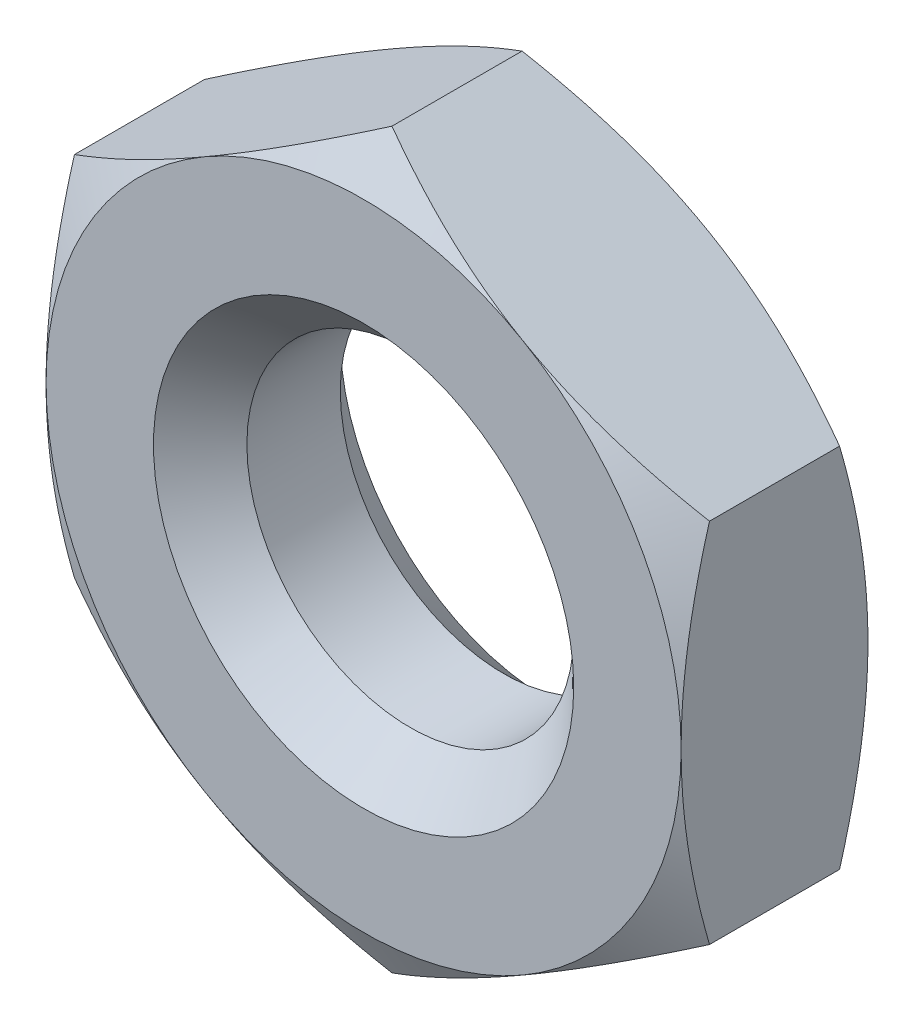
from build123d import *

# Parameters (mm, degrees)
SKETCH_1_R      = 4.375
EXTRUDE_1_DEPTH = 5
CHAMFER_1_SIZE  = 1.25


with BuildPart() as part:
    # Эскиз1 → Бобышка-Вытянуть1 (new body)
    with BuildSketch(Plane.XY):
        Polygon((8.5, -4.907477288), (8.5, 4.907477288), (0, 9.814954576), (-8.5, 4.907477288), (-8.5, -4.907477288), (0, -9.814954576), align=None)
        Circle(SKETCH_1_R, mode=Mode.SUBTRACT)
    extrude(amount=EXTRUDE_1_DEPTH)

    # Фаска1
    chamfer_1_edges = [part.edges().sort_by_distance(p)[0] for p in [
        (-4.375, 0, 0),
        (-4.375, 0, 5),
    ]]
    chamfer(chamfer_1_edges, length=CHAMFER_1_SIZE)

    # Эскиз3 → Вырез-Повернуть1 (revolve, cut)
    with BuildSketch(Plane(origin=(0, 0, 0), x_dir=(0, 0, -1), z_dir=(1, 0, 0))):
        Polygon((-0.759189379, 9.814954576), (0, 9.814954576), (0, 8.5), align=None)
        Polygon((-4.240810621, 9.814954576), (-5, 8.5), (-5, 9.814954576), align=None)
    revolve(axis=Axis((0, 0, 0), (0, 0, 1)), mode=Mode.SUBTRACT)


solid = part.part
